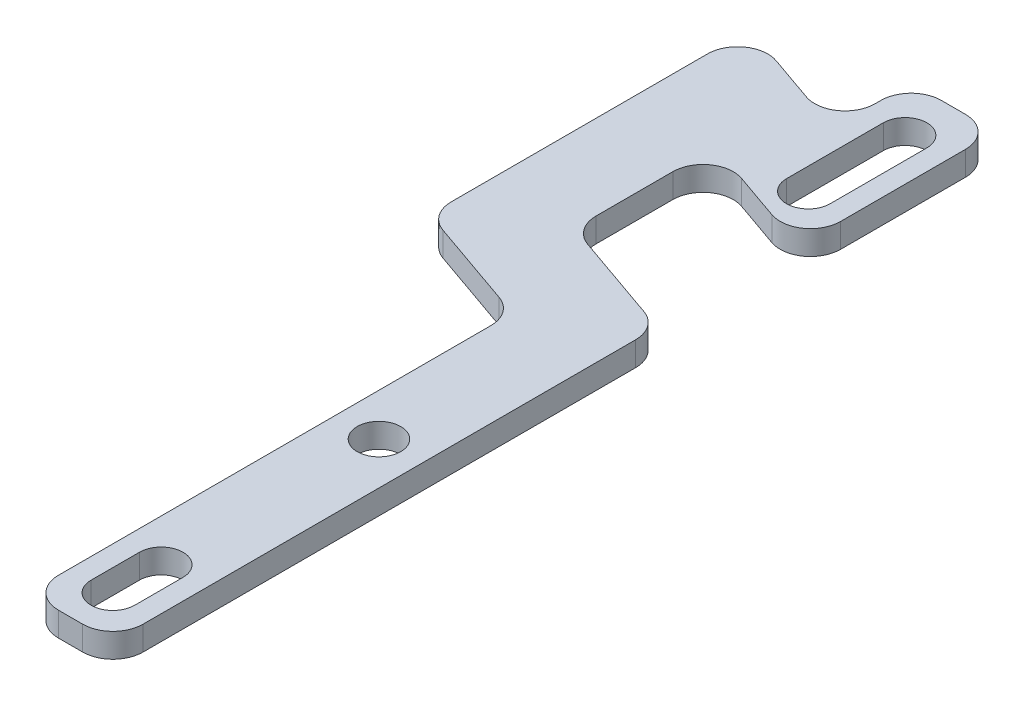
from build123d import *

# Parameters (mm, degrees)
SKETCH_1_R      = 3.6
EXTRUDE_1_DEPTH = 4


with BuildPart() as part:
    # Эскиз1 → Бобышка-Вытянуть1 (new body)
    with BuildSketch(Plane.XZ.offset(-165.322557711)):
        with BuildLine():
            Line((-231.421328736, -112.083155458), (-235.069374415, -113.356756687))
            ThreePointArc((-235.069374415, -113.356756687), (-237.498106164, -115.18254085), (-238.421328736, -118.077344091))
            Line((-238.421328736, -118.077344091), (-238.421328736, -130.787626703))
            ThreePointArc((-238.421328736, -130.787626703), (-236.316131977, -134.864404131), (-231.773283057, -135.508214107))
            Line((-231.773283057, -135.508214107), (-231.421328736, -135.385340246))
            Line((-231.421328736, -135.385340246), (-224.069374415, -132.81863498))
            ThreePointArc((-224.069374415, -132.81863498), (-219.526525495, -133.462444956), (-217.421328736, -137.539222384))
            Line((-217.421328736, -137.539222384), (-217.421328736, -158.195492647))
            ThreePointArc((-217.421328736, -158.195492647), (-218.88579483, -161.731026553), (-222.421328736, -163.195492647))
            Line((-222.421328736, -163.195492647), (-226.421328736, -163.195492647))
            ThreePointArc((-226.421328736, -163.195492647), (-229.956862642, -161.731026553), (-231.421328736, -158.195492647))
            Line((-231.421328736, -158.195492647), (-231.421328736, -157.255548243))
            ThreePointArc((-231.421328736, -157.255548243), (-233.526525495, -153.178770815), (-238.069374415, -152.534960839))
            Line((-238.069374415, -152.534960839), (-245.773283057, -155.224539965))
            ThreePointArc((-245.773283057, -155.224539965), (-250.316131977, -154.580729989), (-252.421328736, -150.503952561))
            Line((-252.421328736, -150.503952561), (-252.421328736, -108.136343856))
            ThreePointArc((-252.421328736, -108.136343856), (-251.498106164, -105.241540615), (-249.069374415, -103.415756451))
            Line((-249.069374415, -103.415756451), (-234.773283057, -98.424722589))
            ThreePointArc((-234.773283057, -98.424722589), (-232.344551308, -96.598938425), (-231.421328736, -93.704135185))
            Line((-231.421328736, -93.704135185), (-231.421328736, -22.195492647))
            ThreePointArc((-231.421328736, -22.195492647), (-229.956862642, -18.659958741), (-226.421328736, -17.195492647))
            Line((-226.421328736, -17.195492647), (-222.421328736, -17.195492647))
            ThreePointArc((-222.421328736, -17.195492647), (-218.88579483, -18.659958741), (-217.421328736, -22.195492647))
            Line((-217.421328736, -22.195492647), (-217.421328736, -103.64513542))
            ThreePointArc((-217.421328736, -103.64513542), (-218.344551308, -106.539938661), (-220.773283057, -108.365722824))
            Line((-220.773283057, -108.365722824), (-231.421328736, -112.083155458))
        make_face()
        with Locations((-224.421328736, -68.195492647)):
            Circle(SKETCH_1_R, mode=Mode.SUBTRACT)
        with BuildLine():
            Line((-228.021328736, -139.195492647), (-228.021328736, -155.195492647))
            ThreePointArc((-228.021328736, -155.195492647), (-224.421328736, -158.795492647), (-220.821328736, -155.195492647))
            Line((-220.821328736, -155.195492647), (-220.821328736, -139.195492647))
            ThreePointArc((-220.821328736, -139.195492647), (-224.421328736, -135.595492647), (-228.021328736, -139.195492647))
        make_face(mode=Mode.SUBTRACT)
        with BuildLine():
            Line((-228.021328736, -24.195492647), (-228.021328736, -32.195492647))
            ThreePointArc((-228.021328736, -32.195492647), (-224.421328736, -35.795492647), (-220.821328736, -32.195492647))
            Line((-220.821328736, -32.195492647), (-220.821328736, -24.195492647))
            ThreePointArc((-220.821328736, -24.195492647), (-224.421328736, -20.595492647), (-228.021328736, -24.195492647))
        make_face(mode=Mode.SUBTRACT)
    extrude(amount=EXTRUDE_1_DEPTH)


solid = part.part
